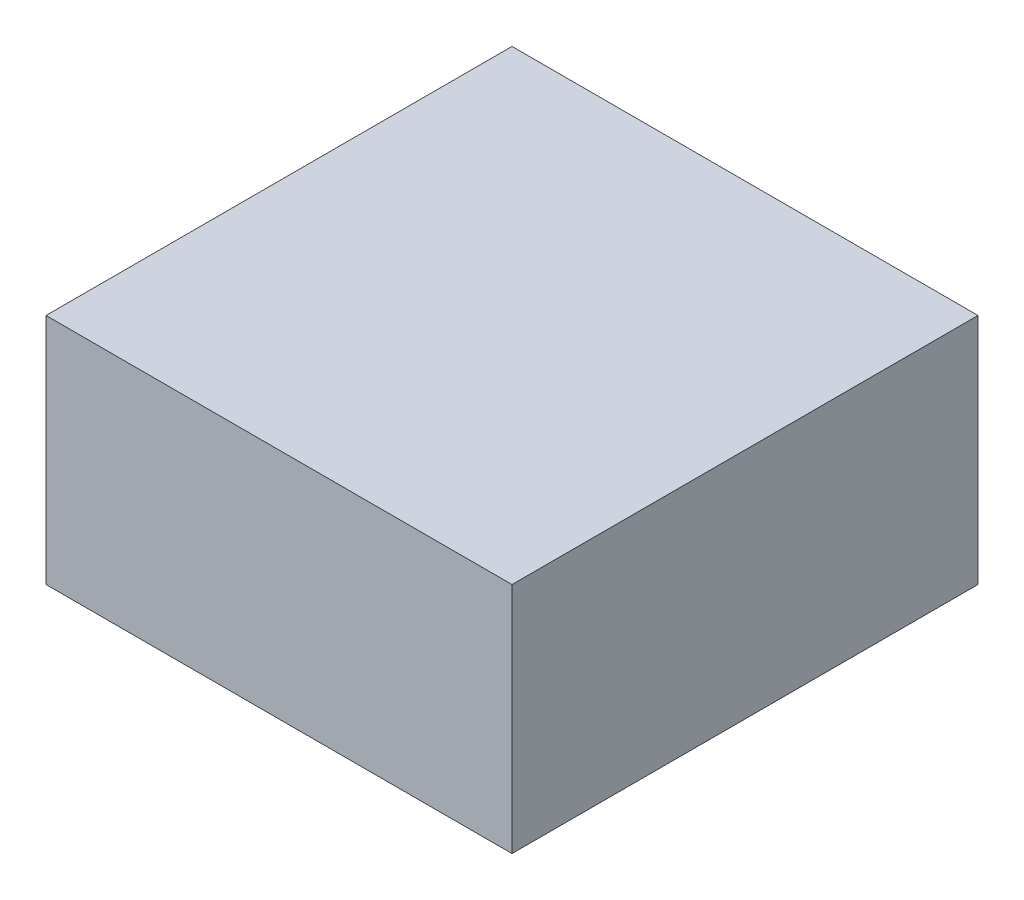
from build123d import *

# Parameters (mm, degrees)
SKETCH1_W           = 2
SKETCH1_H           = 2
BOSS_EXTRUDE1_DEPTH = 1


with BuildPart() as part:
    # Sketch1 → Boss-Extrude1 (new body)
    with BuildSketch(Plane(origin=(0, 0, 0), x_dir=(1, 0, 0), z_dir=(0, 1, 0))):
        with Locations((1, 1)):
            Rectangle(SKETCH1_W, SKETCH1_H)
    extrude(amount=BOSS_EXTRUDE1_DEPTH)


solid = part.part
